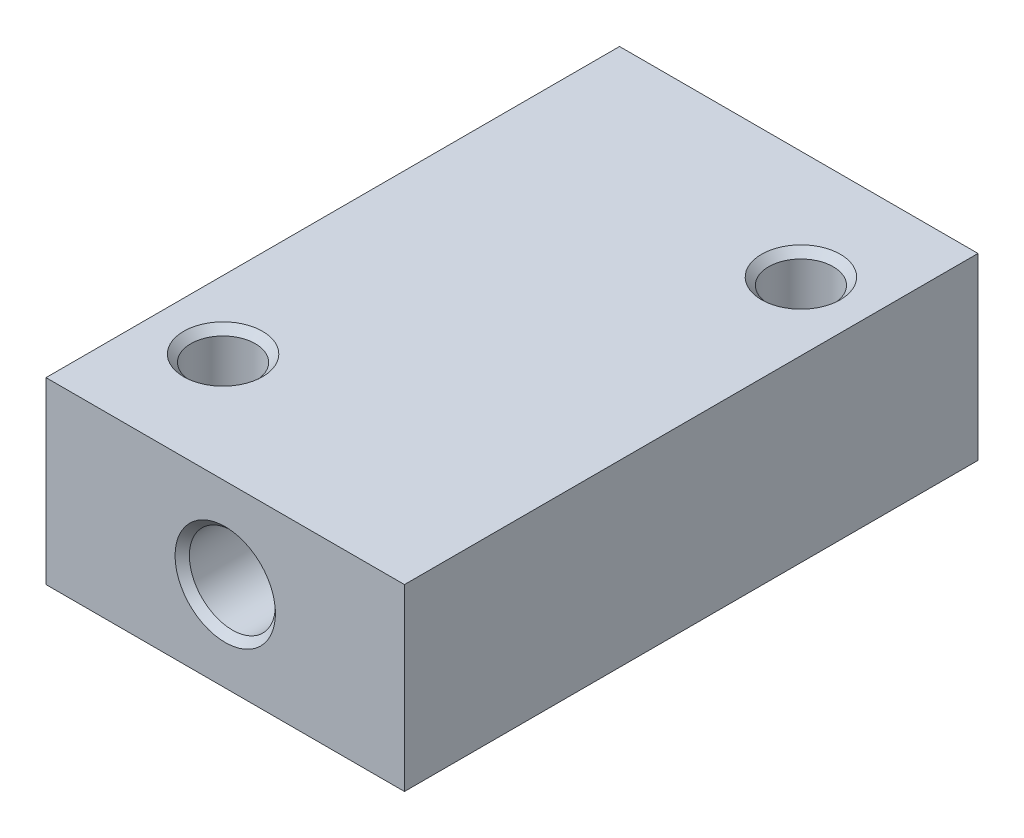
from build123d import *

# Parameters (mm, degrees)
SKETCH1_W           = 50
SKETCH1_H           = 80
SKETCH1_R           = 4.5
BOSS_EXTRUDE1_DEPTH = 25
SKETCH2_R           = 6
CUT_EXTRUDE1_DEPTH  = 88.464278423
CHAMFER1_SIZE       = 1


with BuildPart() as part:
    # Sketch1 → Boss-Extrude1 (new body)
    with BuildSketch(Plane(origin=(0, 0, 0), x_dir=(1, 0, 0), z_dir=(0, 1, 0))):
        Rectangle(SKETCH1_W, SKETCH1_H)
        with Locations((15.5, 24.8)):
            Circle(SKETCH1_R, mode=Mode.SUBTRACT)
        with Locations((-15.5, -24.8)):
            Circle(SKETCH1_R, mode=Mode.SUBTRACT)
    extrude(amount=BOSS_EXTRUDE1_DEPTH)

    # Sketch2 → Cut-Extrude1 (cut, through all)
    with BuildSketch(Plane.XY.offset(40)):
        with Locations((0, 12.5)):
            Circle(SKETCH2_R)
    extrude(amount=-CUT_EXTRUDE1_DEPTH, mode=Mode.SUBTRACT)

    # Chamfer1
    chamfer1_edges = [part.edges().sort_by_distance(p)[0] for p in [
        (11, 0, -24.8),
        (-20, 0, 24.8),
        (11, 25, -24.8),
        (-20, 25, 24.8),
        (-6, 12.5, -40),
        (-6, 12.5, 40),
    ]]
    chamfer(chamfer1_edges, length=CHAMFER1_SIZE)


solid = part.part
